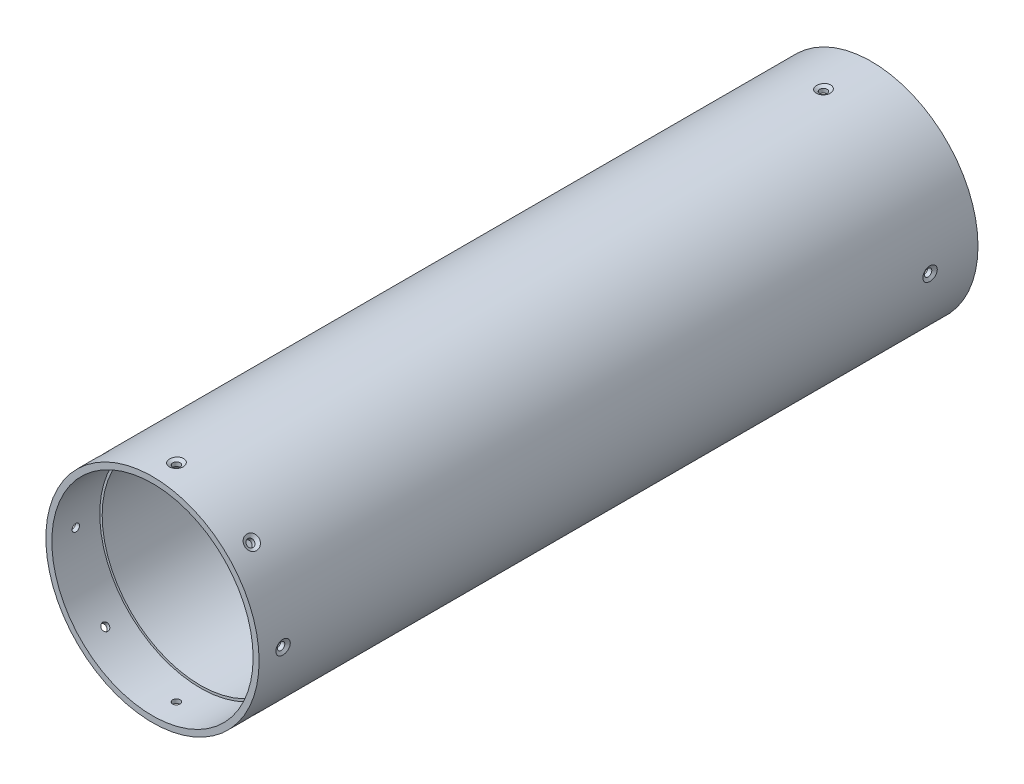
from build123d import *

# Parameters (mm, degrees)
ESQUISSE1_R                  = 44.5
ESQUISSE1_R_2                = 42
BOSS_EXTRU_1_DEPTH           = 300
D_GAGEMENT_M31_D             = 3.1
D_GAGEMENT_M31_CSINK_D       = 6
D_GAGEMENT_M31_CSINK_ANGLE   = 120
R_P_TITION_CIRCULAIRE1_COUNT = 4
D_GAGEMENT_M2_52_D           = 3.1
D_GAGEMENT_M2_52_CSINK_D     = 6
D_GAGEMENT_M2_52_CSINK_ANGLE = 120
R_P_TITION_CIRCULAIRE2_COUNT = 8
ESQUISSE5_W                  = 1
ESQUISSE5_H                  = 253


with BuildPart() as part:
    # Esquisse1 → Boss.-Extru.1 (new body)
    with BuildSketch(Plane.XY):
        Circle(ESQUISSE1_R)
        Circle(ESQUISSE1_R_2, mode=Mode.SUBTRACT)
    extrude(amount=BOSS_EXTRU_1_DEPTH)

    # Dégagement M31 (through all)
    with Locations(Plane(origin=(-44.5, 0, 20), x_dir=(0, 0, -1), z_dir=(-1, 0, 0))):
        with Locations((0, 0)):
            d_gagement_m31 = CounterSinkHole(D_GAGEMENT_M31_D / 2, D_GAGEMENT_M31_CSINK_D / 2, counter_sink_angle=D_GAGEMENT_M31_CSINK_ANGLE)

    # Répétition circulaire1: Dégagement M31 ×4 about axis
    r_p_tition_circulaire1_axis = Axis((0, 0, 0), (0, 0, 1))
    for i in range(1, R_P_TITION_CIRCULAIRE1_COUNT):
        add(d_gagement_m31.rotate(r_p_tition_circulaire1_axis, i * 360 / R_P_TITION_CIRCULAIRE1_COUNT), mode=Mode.SUBTRACT)

    # Dégagement M2.52 (through all)
    with Locations(Plane(origin=(-44.5, 0, 290), x_dir=(0, -1, 0), z_dir=(-1, 0, 0))):
        with Locations((0, 0)):
            d_gagement_m2_52 = CounterSinkHole(D_GAGEMENT_M2_52_D / 2, D_GAGEMENT_M2_52_CSINK_D / 2, counter_sink_angle=D_GAGEMENT_M2_52_CSINK_ANGLE)

    # Répétition circulaire2: Dégagement M2.52 ×8 about axis
    r_p_tition_circulaire2_axis = Axis((0, 0, 300), (0, 0, 1))
    for i in range(1, R_P_TITION_CIRCULAIRE2_COUNT):
        add(d_gagement_m2_52.rotate(r_p_tition_circulaire2_axis, i * 360 / R_P_TITION_CIRCULAIRE2_COUNT), mode=Mode.SUBTRACT)

    # Esquisse5 → Révolution1 (revolve)
    with BuildSketch(Plane(origin=(0, 0, 0), x_dir=(1, 0, 0), z_dir=(0, 1, 0))):
        with Locations((41.5, -153.5)):
            Rectangle(ESQUISSE5_W, ESQUISSE5_H)
    revolve(axis=Axis((0, 0, 328.749949278), (0, 0, -1)))


solid = part.part
